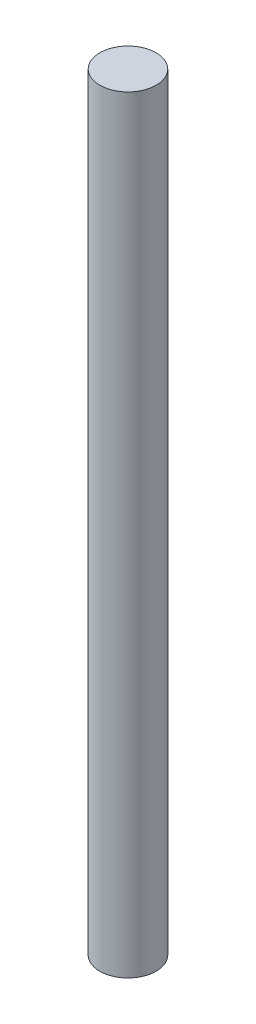
from build123d import *

# Parameters (mm, degrees)
CROQUIS1_R              = 3.165
SALIENTE_EXTRUIR1_DEPTH = 86.28


with BuildPart() as part:
    # Croquis1 → Saliente-Extruir1 (new body)
    with BuildSketch(Plane(origin=(0, 0, 0), x_dir=(1, 0, 0), z_dir=(0, 1, 0))):
        Circle(CROQUIS1_R)
    extrude(amount=SALIENTE_EXTRUIR1_DEPTH)


solid = part.part
